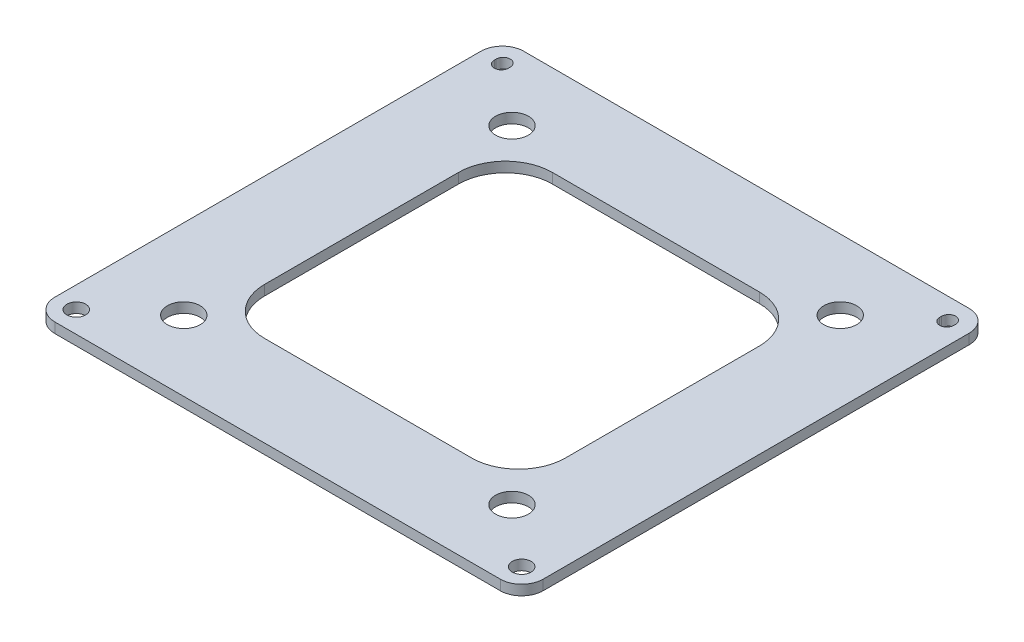
from build123d import *

# Parameters (mm, degrees)
SKETCH2_R           = 2
SKETCH2_R_2         = 3.5
BOSS_EXTRUDE1_DEPTH = 2.15


with BuildPart() as part:
    # Sketch2 → Boss-Extrude1 (new body)
    with BuildSketch(Plane(origin=(0, 0, 0), x_dir=(1, 0, 0), z_dir=(0, 1, 0))):
        with BuildLine():
            Line((-52.075, 45.425), (-52.075, -45.425))
            ThreePointArc((-52.075, -45.425), (-50.735013524, -48.660013524), (-47.5, -50))
            Line((-47.5, -50), (47.5, -50))
            ThreePointArc((47.5, -50), (50.735013524, -48.660013524), (52.075, -45.425))
            Line((52.075, -45.425), (52.075, 45.425))
            ThreePointArc((52.075, 45.425), (50.735013524, 48.660013524), (47.5, 50))
            Line((47.5, 50), (-47.5, 50))
            ThreePointArc((-47.5, 50), (-50.735013524, 48.660013524), (-52.075, 45.425))
        make_face()
        with Locations((47.5, -45.425)):
            Circle(SKETCH2_R, mode=Mode.SUBTRACT)
        with Locations((-47.5, -45.425)):
            Circle(SKETCH2_R, mode=Mode.SUBTRACT)
        with Locations((-35, 35)):
            Circle(SKETCH2_R_2, mode=Mode.SUBTRACT)
        with Locations((35, 35)):
            Circle(SKETCH2_R_2, mode=Mode.SUBTRACT)
        with Locations((35, -35)):
            Circle(SKETCH2_R_2, mode=Mode.SUBTRACT)
        with Locations((-35, -35)):
            Circle(SKETCH2_R_2, mode=Mode.SUBTRACT)
        with BuildLine():
            Line((-49, 45.225), (-49, 45.625))
            ThreePointArc((-49, 45.625), (-47.5, 47.125), (-46, 45.625))
            Line((-46, 45.625), (-46, 45.225))
            ThreePointArc((-46, 45.225), (-47.5, 43.725), (-49, 45.225))
        make_face(mode=Mode.SUBTRACT)
        with BuildLine():
            Line((46, 45.225), (46, 45.625))
            ThreePointArc((46, 45.625), (47.5, 47.125), (49, 45.625))
            Line((49, 45.625), (49, 45.225))
            ThreePointArc((49, 45.225), (47.5, 43.725), (46, 45.225))
        make_face(mode=Mode.SUBTRACT)
        with BuildLine():
            Line((-22.075, -30.673828947), (22.075, -30.673828947))
            ThreePointArc((22.075, -30.673828947), (29.146067812, -27.744896759), (32.075, -20.673828947))
            Line((32.075, -20.673828947), (32.075, 20.673828947))
            ThreePointArc((32.075, 20.673828947), (29.146067812, 27.744896759), (22.075, 30.673828947))
            Line((22.075, 30.673828947), (-22.075, 30.673828947))
            ThreePointArc((-22.075, 30.673828947), (-29.146067812, 27.744896759), (-32.075, 20.673828947))
            Line((-32.075, 20.673828947), (-32.075, -20.673828947))
            ThreePointArc((-32.075, -20.673828947), (-29.146067812, -27.744896759), (-22.075, -30.673828947))
        make_face(mode=Mode.SUBTRACT)
    extrude(amount=BOSS_EXTRUDE1_DEPTH)


solid = part.part
